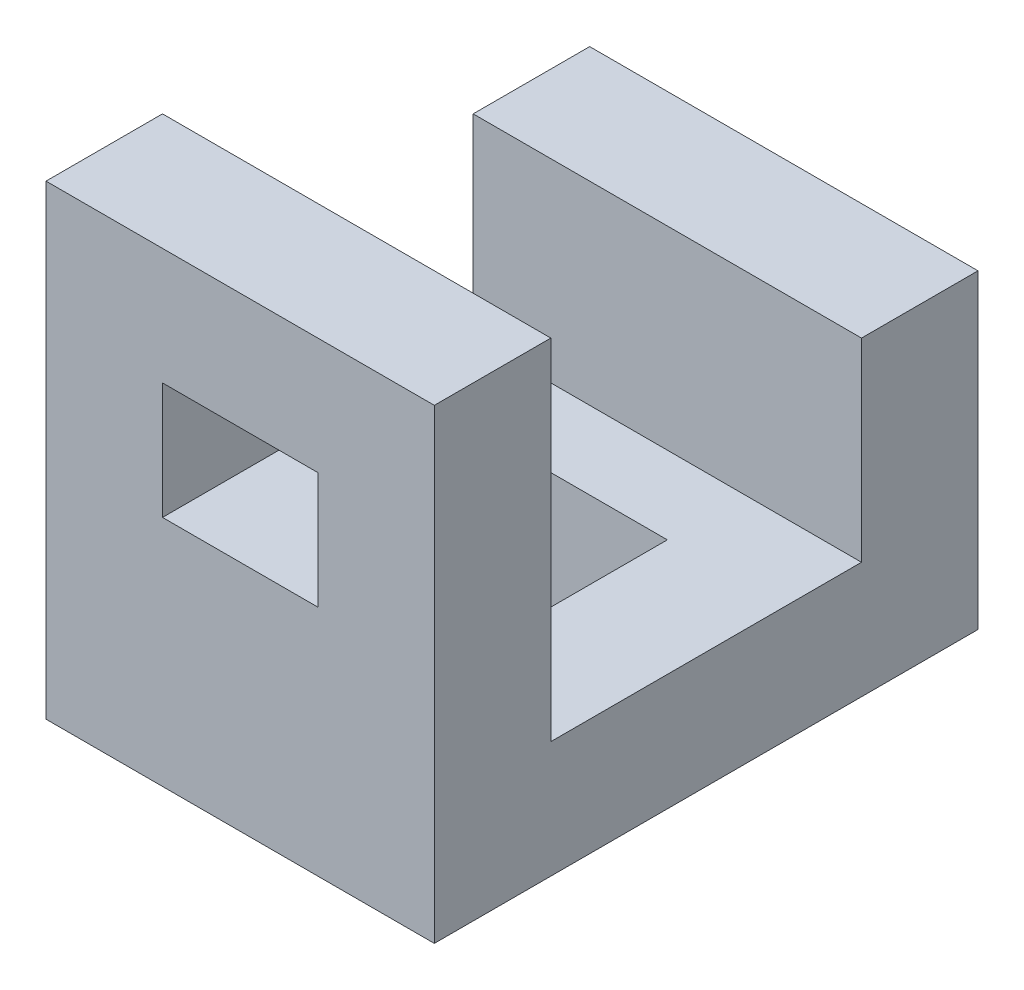
from build123d import *

# Parameters (mm, degrees)
SKETCH1_W           = 50
SKETCH1_H           = 70
BOSS_EXTRUDE1_DEPTH = 60
SKETCH2_W           = 20
SKETCH2_H           = 20
CUT_EXTRUDE1_DEPTH  = 60
CUT_EXTRUDE2_DEPTH  = 50
SKETCH4_W           = 20
SKETCH4_H           = 15
CUT_EXTRUDE3_DEPTH  = 50


with BuildPart() as part:
    # Sketch1 → Boss-Extrude1 (new body)
    with BuildSketch(Plane(origin=(0, 0, 0), x_dir=(1, 0, 0), z_dir=(0, 1, 0))):
        with Locations((25, 35)):
            Rectangle(SKETCH1_W, SKETCH1_H)
    extrude(amount=BOSS_EXTRUDE1_DEPTH)

    # Sketch2 → Cut-Extrude1 (cut)
    with BuildSketch(Plane.XZ):
        with Locations((25, -35)):
            Rectangle(SKETCH2_W, SKETCH2_H)
    extrude(amount=-CUT_EXTRUDE1_DEPTH, mode=Mode.SUBTRACT)

    # Sketch3 → Cut-Extrude2 (cut)
    with BuildSketch(Plane.ZY):
        Polygon((-15, 60), (-15, 15), (-55, 15), (-55, 40), (-70, 40), (-70, 60), align=None)
    extrude(amount=-CUT_EXTRUDE2_DEPTH, mode=Mode.SUBTRACT)

    # Sketch4 → Cut-Extrude3 (cut)
    with BuildSketch(Plane.XY):
        with Locations((25, 37.5)):
            Rectangle(SKETCH4_W, SKETCH4_H)
    extrude(amount=-CUT_EXTRUDE3_DEPTH, mode=Mode.SUBTRACT)


solid = part.part
